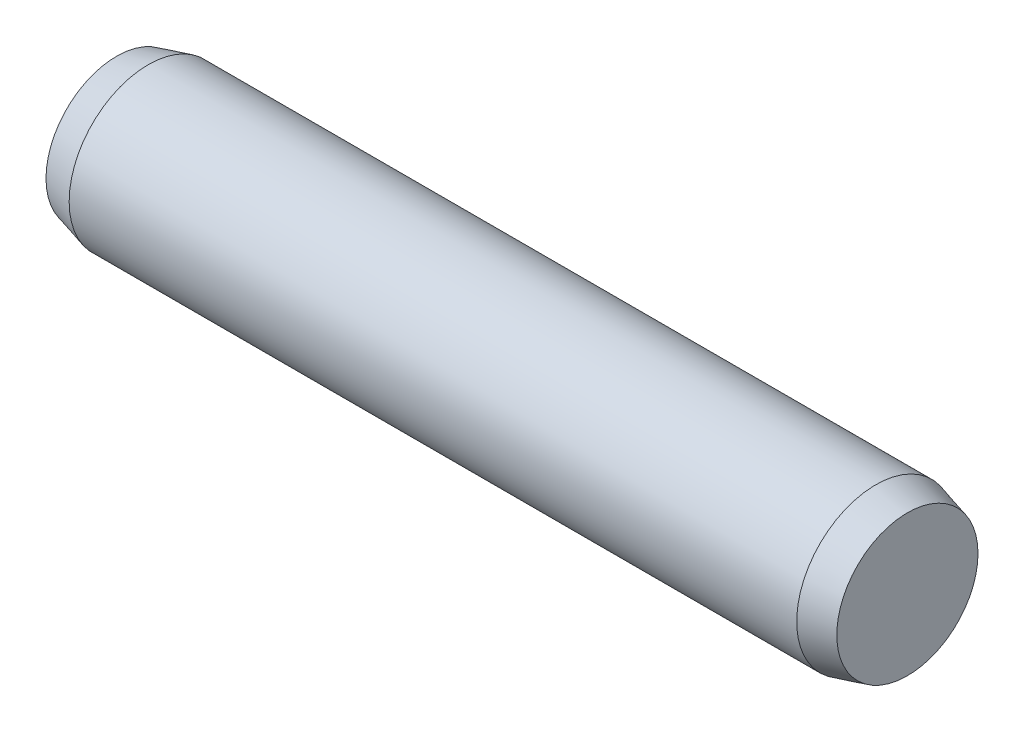
from build123d import *

# Parameters (mm, degrees)
SKETCH2_R           = 3
EXTRUDE1_DEPTH      = 13.8
EXTRUDE1_DEPTH_BACK = 13.8
SKETCH3_R           = 3
EXTRUDE2_DEPTH      = 1.2
EXTRUDE2_TAPER      = 15
SKETCH4_R           = 3
EXTRUDE3_DEPTH      = 1.2
EXTRUDE3_TAPER      = 15


with BuildPart() as part:
    # Sketch2 → Extrude1 (new body, two sides)
    with BuildSketch(Plane(origin=(0, 0, 0), x_dir=(0, 0, -1), z_dir=(1, 0, 0))) as extrude1_sk:
        Circle(SKETCH2_R)
    extrude(amount=EXTRUDE1_DEPTH)
    extrude(extrude1_sk.sketch, amount=-EXTRUDE1_DEPTH_BACK)

    # Sketch3 → Extrude2 (add)
    with BuildSketch(Plane(origin=(13.8, 0, 0), x_dir=(0, 0, -1), z_dir=(1, 0, 0))):
        Circle(SKETCH3_R)
    extrude(amount=EXTRUDE2_DEPTH, taper=EXTRUDE2_TAPER)

    # Sketch4 → Extrude3 (add)
    with BuildSketch(Plane.ZY.offset(13.8)):
        Circle(SKETCH4_R)
    extrude(amount=EXTRUDE3_DEPTH, taper=EXTRUDE3_TAPER)


solid = part.part
